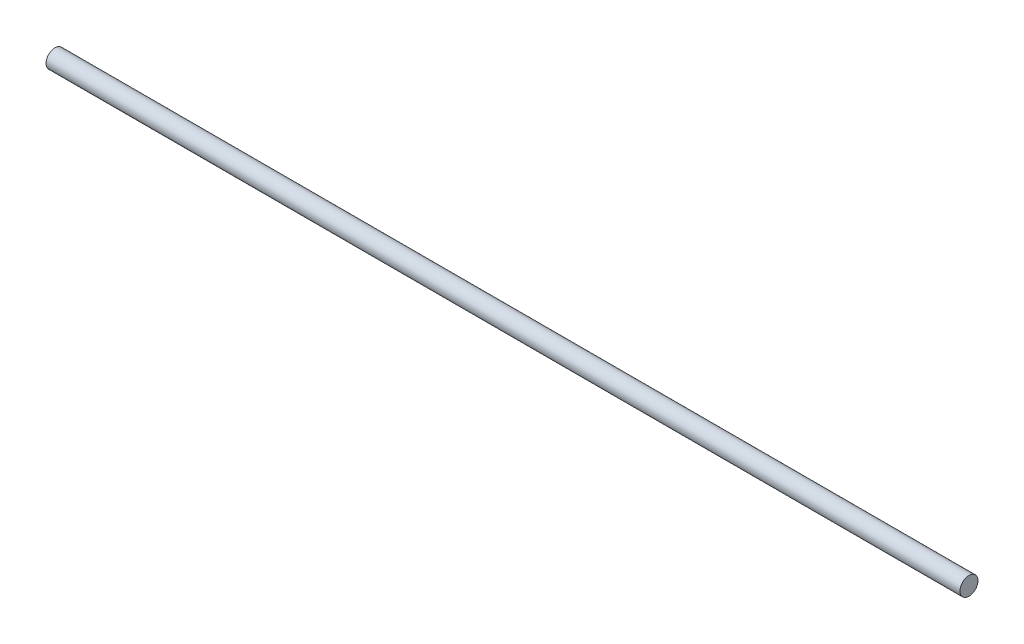
from build123d import *

# Parameters (mm, degrees)
SKETCH1_R           = 4
BOSS_EXTRUDE1_DEPTH = 202.5


with BuildPart() as part:
    # Sketch1 → Boss-Extrude1 (new body, symmetric)
    with BuildSketch(Plane(origin=(0, 0, 0), x_dir=(0, 0, -1), z_dir=(1, 0, 0))):
        Circle(SKETCH1_R)
    extrude(amount=BOSS_EXTRUDE1_DEPTH, both=True)


solid = part.part
